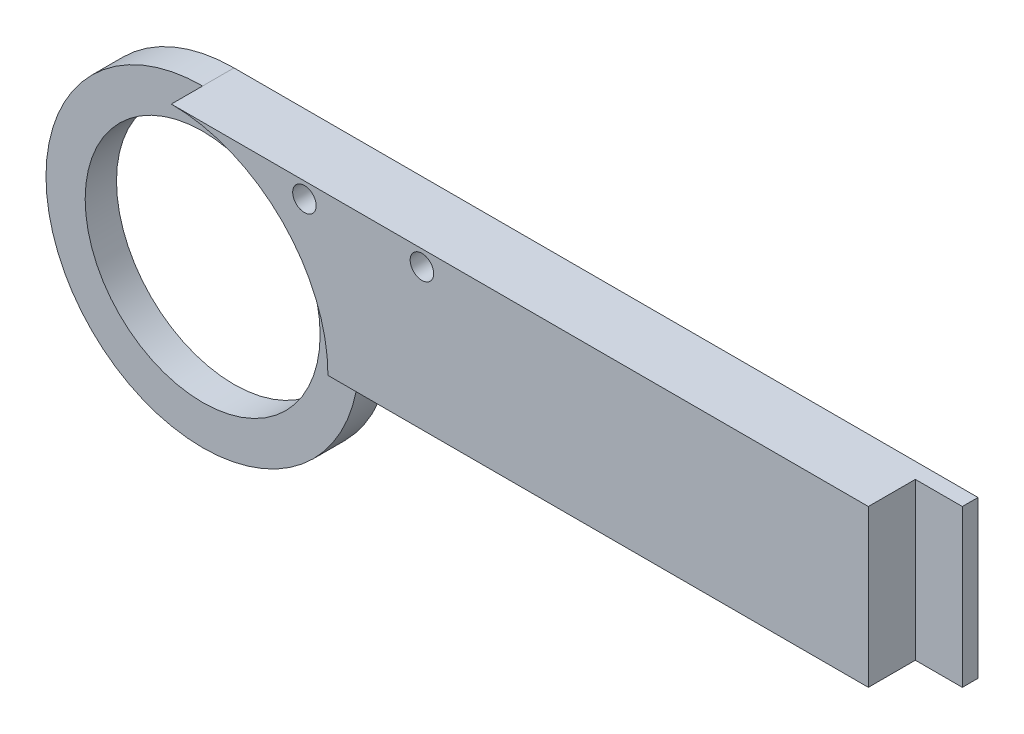
from build123d import *

# Parameters (mm, degrees)
BOSS_EXTRU_1_DEPTH      = 8
ESQUISSE2_R             = 20
ESQUISSE2_R_2           = 15
ENL_V_MAT_EXTRU_1_DEPTH = 4
ESQUISSE3_W             = 9.17
ESQUISSE3_H             = 20
BOSS_EXTRU_2_DEPTH      = 8
ESQUISSE7_W             = 6
ESQUISSE7_H             = 20
ENL_V_MAT_EXTRU_5_DEPTH = 6
ESQUISSE8_R             = 1.5
ENL_V_MAT_EXTRU_6_DEPTH = 10


with BuildPart() as part:
    # Esquisse1 → Boss.-Extru.1 (new body)
    with BuildSketch(Plane.XY):
        with BuildLine():
            Line((42.613906887, 3.786407767), (42.613906887, 23.786407767))
            Line((42.613906887, 23.786407767), (-43.211335831, 23.786407767))
            ThreePointArc((-43.211335831, 23.786407767), (-29.069200208, 17.928543391), (-23.211335831, 3.786407767))
            Line((-23.211335831, 3.786407767), (42.613906887, 3.786407767))
        make_face()
        with BuildLine():
            ThreePointArc((-23.211335831, 3.786407767), (-29.069200208, 17.928543391), (-43.211335831, 23.786407767))
            Line((-43.211335831, 23.786407767), (-43.211335831, 18.786407767))
            ThreePointArc((-43.211335831, 18.786407767), (-32.604734113, 14.393009485), (-28.211335831, 3.786407767))
            Line((-28.211335831, 3.786407767), (-23.211335831, 3.786407767))
        make_face()
        with BuildLine():
            Line((-43.211335831, 18.786407767), (-43.211335831, 23.786407767))
            ThreePointArc((-43.211335831, 23.786407767), (-57.353471455, -10.355727857), (-23.211335831, 3.786407767))
            Line((-23.211335831, 3.786407767), (-28.211335831, 3.786407767))
            ThreePointArc((-28.211335831, 3.786407767), (-53.817937549, -6.820193951), (-43.211335831, 18.786407767))
        make_face()
    extrude(amount=BOSS_EXTRU_1_DEPTH)

    # Esquisse2 → Enlèv. mat.-Extru.1 (cut)
    with BuildSketch(Plane.XY.offset(8)):
        with Locations((-43.211335831, 3.786407767)):
            Circle(ESQUISSE2_R)
        with Locations((-43.211335831, 3.786407767)):
            Circle(ESQUISSE2_R_2, mode=Mode.SUBTRACT)
    extrude(amount=-ENL_V_MAT_EXTRU_1_DEPTH, mode=Mode.SUBTRACT)

    # Esquisse3 → Boss.-Extru.2 (add)
    with BuildSketch(Plane.XY.offset(8)):
        with Locations((47.198906887, 13.786407767)):
            Rectangle(ESQUISSE3_W, ESQUISSE3_H)
    extrude(amount=-BOSS_EXTRU_2_DEPTH)

    # Esquisse7 → Enlèv. mat.-Extru.5 (cut)
    with BuildSketch(Plane.XY.offset(8)):
        with Locations((48.783906887, 13.786407767)):
            Rectangle(ESQUISSE7_W, ESQUISSE7_H)
    extrude(amount=-ENL_V_MAT_EXTRU_5_DEPTH, mode=Mode.SUBTRACT)

    # Esquisse8 → Enlèv. mat.-Extru.6 (cut)
    with BuildSketch(Plane.XY.offset(8)):
        with Locations((-26.216093113, 21.786407767)):
            Circle(ESQUISSE8_R)
        with Locations((-11.216093113, 21.786407767)):
            Circle(ESQUISSE8_R)
    extrude(amount=-ENL_V_MAT_EXTRU_6_DEPTH, mode=Mode.SUBTRACT)


solid = part.part
